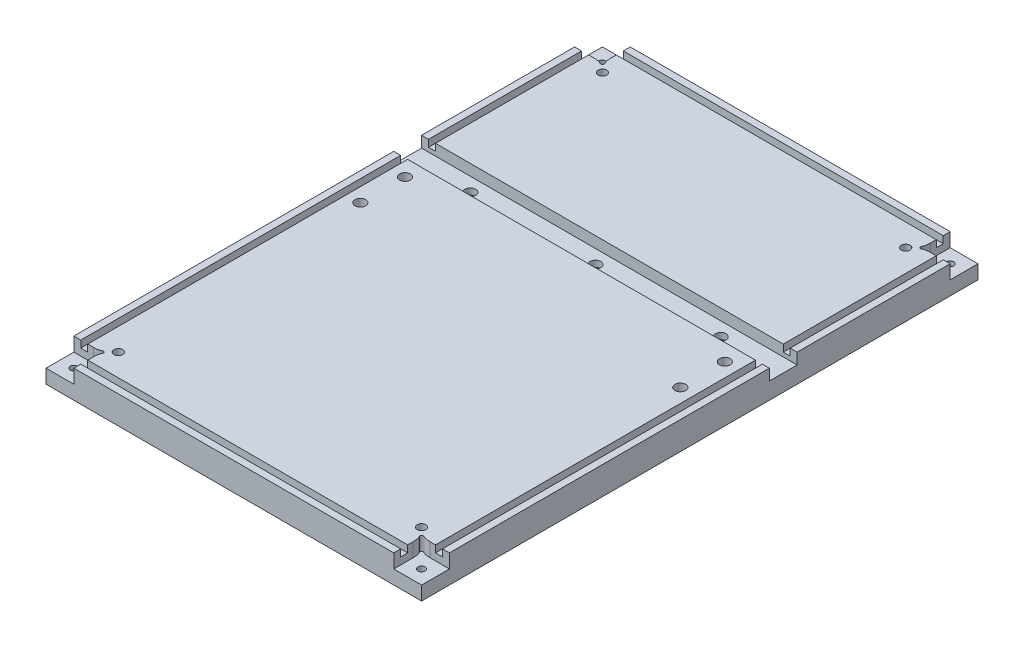
from build123d import *

# Parameters (mm, degrees)
BASE_W                                           = 342.9
BASE_H                                           = 508
BOSS_EXTRUDE1_DEPTH                              = 25.4
SKETCH2_W                                        = 406.4
SKETCH2_H                                        = 25.4
CUT_EXTRUDE1_DEPTH                               = 10.16
CBORE_FOR_3_8_SOCKET_HEAD_CAP_SCREW4_D           = 9.8044
CBORE_FOR_3_8_SOCKET_HEAD_CAP_SCREW4_DEPTH       = 15.24
CBORE_FOR_3_8_SOCKET_HEAD_CAP_SCREW4_CBORE_D     = 15.875
CBORE_FOR_3_8_SOCKET_HEAD_CAP_SCREW4_CBORE_DEPTH = 9.525
CBORE_FOR_3_8_SOCKET_HEAD_CAP_SCREW3_D           = 9.8044
CBORE_FOR_3_8_SOCKET_HEAD_CAP_SCREW3_DEPTH       = 25.4
CBORE_FOR_3_8_SOCKET_HEAD_CAP_SCREW3_CBORE_D     = 15.875
CBORE_FOR_3_8_SOCKET_HEAD_CAP_SCREW3_CBORE_DEPTH = 15.24
CBORE_FOR_1_4_SOCKET_HEAD_CAP_SCREW1_D           = 6.5278
CBORE_FOR_1_4_SOCKET_HEAD_CAP_SCREW1_DEPTH       = 25.4
CBORE_FOR_1_4_SOCKET_HEAD_CAP_SCREW1_CBORE_D     = 11.1125
CBORE_FOR_1_4_SOCKET_HEAD_CAP_SCREW1_CBORE_DEPTH = 6.35
CUT_EXTRUDE3_DEPTH                               = 12.7
SKETCH10_W                                       = 6.35
SKETCH10_H                                       = 457.2
SKETCH10_W_2                                     = 292.1
SKETCH10_H_2                                     = 6.35
CUT_EXTRUDE4_DEPTH                               = 6.35
F_3_8_16_TAPPED_HOLE2_D                          = 7.9375
F_3_8_16_TAPPED_HOLE2_DEPTH                      = 25.4
SKETCH19_R                                       = 9.525
CUT_EXTRUDE5_DEPTH                               = 1.27


with BuildPart() as part:
    # Base → Boss-Extrude1 (new body)
    with BuildSketch(Plane(origin=(0, 0, 0), x_dir=(1, 0, 0), z_dir=(0, 1, 0))):
        with Locations((-30.52641196, -120.249169435)):
            Rectangle(BASE_W, BASE_H)
    extrude(amount=BOSS_EXTRUDE1_DEPTH)

    # Sketch2 → Cut-Extrude1 (cut)
    with BuildSketch(Plane(origin=(0, 25.4, 0), x_dir=(1, 0, 0), z_dir=(0, 1, 0))):
        with Locations((-30.52641196, -44.049169435)):
            Rectangle(SKETCH2_W, SKETCH2_H)
    extrude(amount=-CUT_EXTRUDE1_DEPTH, mode=Mode.SUBTRACT)

    # CBORE for 3/8 Socket Head Cap Screw4
    with Locations(Plane(origin=(83.77358804, 0, 44.049169435), x_dir=(0, 0, -1), z_dir=(0, -1, 0))):
        with Locations((0, 0), (0, -114.3), (0, -228.6)):
            CounterBoreHole(CBORE_FOR_3_8_SOCKET_HEAD_CAP_SCREW4_D / 2, CBORE_FOR_3_8_SOCKET_HEAD_CAP_SCREW4_CBORE_D / 2, CBORE_FOR_3_8_SOCKET_HEAD_CAP_SCREW4_CBORE_DEPTH, depth=CBORE_FOR_3_8_SOCKET_HEAD_CAP_SCREW4_DEPTH)

    # CBORE for 3/8 Socket Head Cap Screw3
    with Locations(Plane(origin=(0, 0, 0), x_dir=(-1, 0, 0), z_dir=(0, -1, 0))):
        with Locations((-115.52358804, -71.989169435), (-115.52358804, -112.629169435), (176.57641196, -71.989169435), (176.57641196, -112.629169435)):
            CounterBoreHole(CBORE_FOR_3_8_SOCKET_HEAD_CAP_SCREW3_D / 2, CBORE_FOR_3_8_SOCKET_HEAD_CAP_SCREW3_CBORE_D / 2, CBORE_FOR_3_8_SOCKET_HEAD_CAP_SCREW3_CBORE_DEPTH, depth=CBORE_FOR_3_8_SOCKET_HEAD_CAP_SCREW3_DEPTH)

    # CBORE for 1/4 Socket Head Cap Screw1
    with Locations(Plane(origin=(128.22358804, 0, 361.549169435), x_dir=(0, 0, -1), z_dir=(0, -1, 0))):
        with Locations((0, 0), (0, -317.5), (482.6, -317.5), (482.6, 0)):
            CounterBoreHole(CBORE_FOR_1_4_SOCKET_HEAD_CAP_SCREW1_D / 2, CBORE_FOR_1_4_SOCKET_HEAD_CAP_SCREW1_CBORE_D / 2, CBORE_FOR_1_4_SOCKET_HEAD_CAP_SCREW1_CBORE_DEPTH, depth=CBORE_FOR_1_4_SOCKET_HEAD_CAP_SCREW1_DEPTH)

    # Sketch8 → Cut-Extrude3 (cut)
    with BuildSketch(Plane(origin=(0, 25.4, 0), x_dir=(1, 0, 0), z_dir=(0, 1, 0))):
        with BuildLine():
            Line((140.92358804, -374.249169435), (115.52358804, -374.249169435))
            Line((115.52358804, -374.249169435), (115.52358804, -356.469169435))
            add(Edge.make_bspline(
                [(115.52358804, -356.469169435), (115.52358804, -353.916782548), (115.309325815, -351.653056376), (114.148772711, -349.642919435)],
                knots=[0, 0, 0, 0, 1, 1, 1, 1], degree=3))
            ThreePointArc((114.148772711, -349.642919435), (114.401056025, -347.72663742), (116.31733804, -347.474354107))
            add(Edge.make_bspline(
                [(123.14358804, -348.849169435), (120.822481832, -348.849169435), (118.327474981, -348.634907211), (116.31733804, -347.474354107)],
                knots=[0, 0, 0, 0, 1, 1, 1, 1], degree=3))
            Line((123.14358804, -348.849169435), (140.92358804, -348.849169435))
            Line((140.92358804, -348.849169435), (140.92358804, -374.249169435))
        make_face()
        with BuildLine():
            Line((-201.97641196, -374.249169435), (-176.57641196, -374.249169435))
            Line((-176.57641196, -374.249169435), (-176.57641196, -356.469169435))
            add(Edge.make_bspline(
                [(-175.201596632, -349.642919435), (-176.794150567, -352.401303766), (-176.57641196, -354.968722974), (-176.57641196, -356.469169435)],
                knots=[0, 0, 0, 0, 1, 1, 1, 1], degree=3))
            ThreePointArc((-175.201596632, -349.642919435), (-175.453879945, -347.72663742), (-177.37016196, -347.474354107))
            add(Edge.make_bspline(
                [(-177.37016196, -347.474354107), (-180.128546291, -349.066908042), (-182.695965499, -348.849169435), (-184.19641196, -348.849169435)],
                knots=[0, 0, 0, 0, 1, 1, 1, 1], degree=3))
            Line((-184.19641196, -348.849169435), (-201.97641196, -348.849169435))
            Line((-201.97641196, -348.849169435), (-201.97641196, -374.249169435))
        make_face()
        with BuildLine():
            Line((-201.97641196, 133.750830565), (-176.57641196, 133.750830565))
            Line((-176.57641196, 133.750830565), (-176.57641196, 115.970830565))
            add(Edge.make_bspline(
                [(-176.57641196, 115.970830565), (-176.57641196, 113.418443678), (-176.362149736, 111.154717506), (-175.201596632, 109.144580565)],
                knots=[0, 0, 0, 0, 1, 1, 1, 1], degree=3))
            ThreePointArc((-175.201596632, 109.144580565), (-175.453879945, 107.22829855), (-177.37016196, 106.976015236))
            add(Edge.make_bspline(
                [(-177.37016196, 106.976015236), (-179.380298901, 108.13656834), (-181.875305752, 108.350830565), (-184.19641196, 108.350830565)],
                knots=[0, 0, 0, 0, 1, 1, 1, 1], degree=3))
            Line((-184.19641196, 108.350830565), (-201.97641196, 108.350830565))
            Line((-201.97641196, 108.350830565), (-201.97641196, 133.750830565))
        make_face()
        with BuildLine():
            Line((140.92358804, 133.750830565), (115.52358804, 133.750830565))
            Line((115.52358804, 133.750830565), (115.52358804, 115.970830565))
            add(Edge.make_bspline(
                [(114.148772711, 109.144580565), (115.309325815, 111.154717506), (115.52358804, 113.649724357), (115.52358804, 115.970830565)],
                knots=[0, 0, 0, 0, 1, 1, 1, 1], degree=3))
            ThreePointArc((114.148772711, 109.144580565), (114.401056025, 107.22829855), (116.31733804, 106.976015236))
            add(Edge.make_bspline(
                [(123.14358804, 108.350830565), (120.822481832, 108.350830565), (118.327474981, 108.13656834), (116.31733804, 106.976015236)],
                knots=[0, 0, 0, 0, 1, 1, 1, 1], degree=3))
            Line((123.14358804, 108.350830565), (140.92358804, 108.350830565))
            Line((140.92358804, 108.350830565), (140.92358804, 133.750830565))
        make_face()
    extrude(amount=-CUT_EXTRUDE3_DEPTH, mode=Mode.SUBTRACT)

    # Sketch10 → Cut-Extrude4 (cut)
    with BuildSketch(Plane(origin=(0, 25.4, 0), x_dir=(1, 0, 0), z_dir=(0, 1, 0))):
        with Locations((131.39858804, -120.249169435)):
            Rectangle(SKETCH10_W, SKETCH10_H)
        with Locations((-192.45141196, -120.249169435)):
            Rectangle(SKETCH10_W, SKETCH10_H)
        with Locations((-30.52641196, 124.225830565)):
            Rectangle(SKETCH10_W_2, SKETCH10_H_2)
        with Locations((-30.52641196, -364.724169435)):
            Rectangle(SKETCH10_W_2, SKETCH10_H_2)
    extrude(amount=-CUT_EXTRUDE4_DEPTH, mode=Mode.SUBTRACT)

    # 3/8-16 Tapped Hole2
    with Locations(Plane(origin=(0, 0, 0), x_dir=(-1, 0, 0), z_dir=(0, -1, 0))):
        with Locations((-107.90358804, -341.229169435), (168.95641196, -341.229169435), (168.95641196, 100.730830565), (-107.90358804, 100.730830565)):
            Hole(F_3_8_16_TAPPED_HOLE2_D / 2, depth=F_3_8_16_TAPPED_HOLE2_DEPTH)

    # Sketch19 → Cut-Extrude5 (cut)
    with BuildSketch(Plane.XZ):
        with Locations((-168.95641196, -100.730830565)):
            Circle(SKETCH19_R)
        with Locations((-168.95641196, 341.229169435)):
            Circle(SKETCH19_R)
        with Locations((107.90358804, 341.229169435)):
            Circle(SKETCH19_R)
        with Locations((108.217263786, -100.730830565)):
            Circle(SKETCH19_R)
    extrude(amount=-CUT_EXTRUDE5_DEPTH, mode=Mode.SUBTRACT)


solid = part.part
